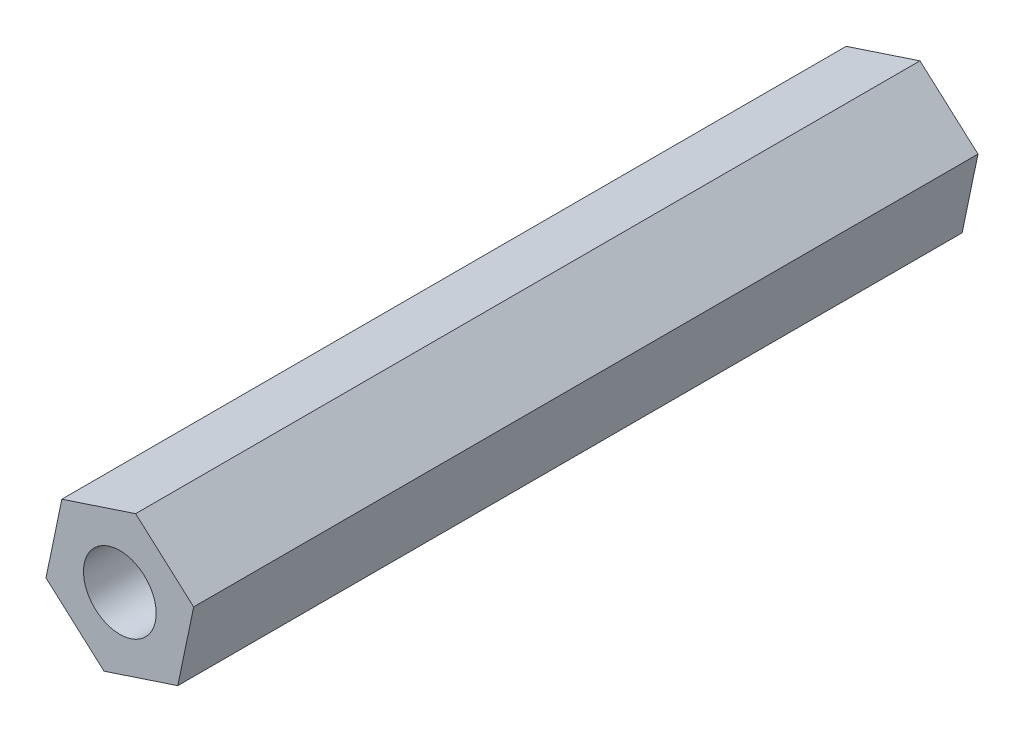
from build123d import *

# Parameters (mm, degrees)
SALIENTE_EXTRUIR1_DEPTH = 36.7
CROQUIS2_R              = 1.7
CORTAR_EXTRUIR1_DEPTH   = 37.7


with BuildPart() as part:
    # Croquis1 → Saliente-Extruir1 (new body)
    with BuildSketch(Plane.XY):
        Polygon((3.454026158, 1.140045307), (0.739704881, 3.561297051), (-2.714321276, 2.421251744), (-3.454026158, -1.140045307), (-0.739704881, -3.561297051), (2.714321276, -2.421251744), align=None)
    extrude(amount=SALIENTE_EXTRUIR1_DEPTH)

    # Croquis2 → Cortar-Extruir1 (cut, through all)
    with BuildSketch(Plane.XY.offset(36.7)):
        Circle(CROQUIS2_R)
    extrude(amount=-CORTAR_EXTRUIR1_DEPTH, mode=Mode.SUBTRACT)


solid = part.part
